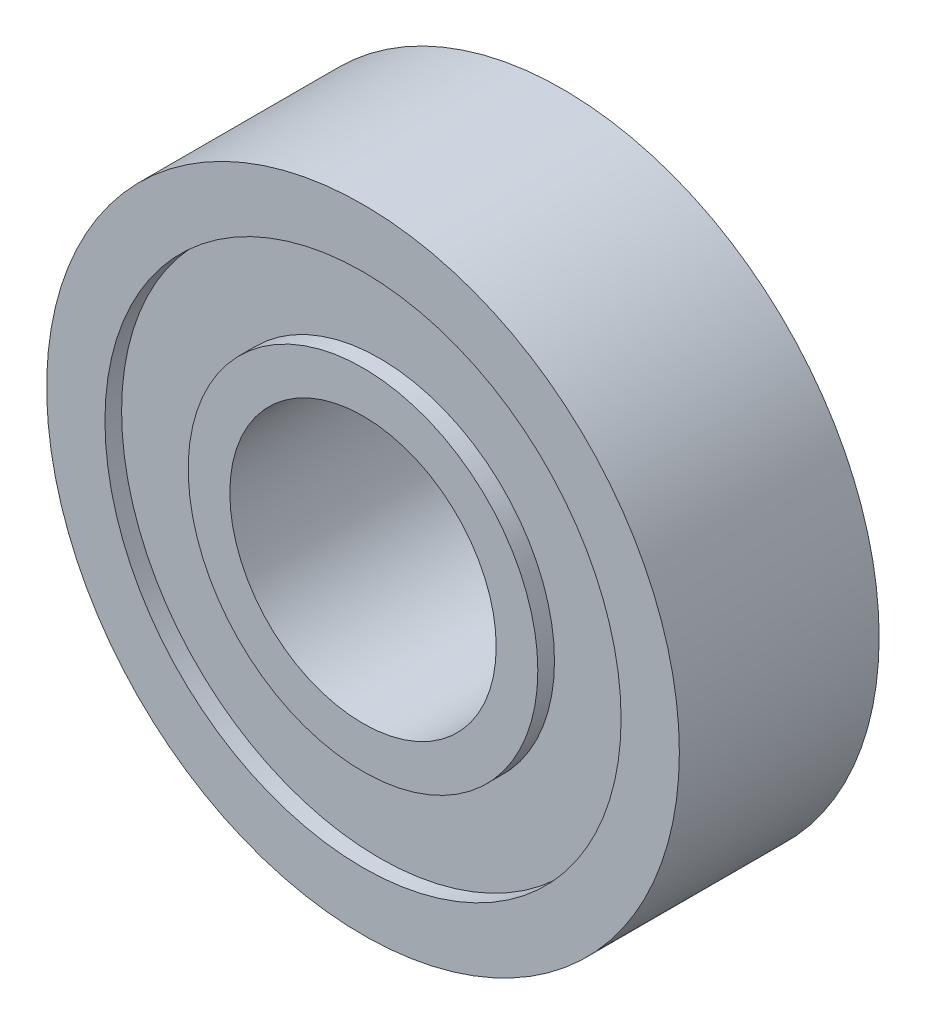
from build123d import *

# Parameters (mm, degrees)
SKETCH_1_R          = 9.5
EXTRUDE_1_DEPTH     = 3
SKETCH_2_R          = 4
CUT_EXTRUDE_1_DEPTH = 7
SKETCH_3_R          = 7.75
SKETCH_3_R_2        = 5.25
CUT_EXTRUDE_2_DEPTH = 0.5


with BuildPart() as part:
    # 草圖1 → 填料-伸長1 (new body, symmetric)
    with BuildSketch(Plane.XY):
        Circle(SKETCH_1_R)
    extrude(amount=EXTRUDE_1_DEPTH, both=True)

    # 草圖2 → 除料-伸長1 (cut, through all)
    with BuildSketch(Plane.XY.offset(3)):
        Circle(SKETCH_2_R)
    extrude(amount=-CUT_EXTRUDE_1_DEPTH, mode=Mode.SUBTRACT)

    # 草圖3 → 除料-伸長2 (cut)
    with BuildSketch(Plane.XY.offset(3)):
        Circle(SKETCH_3_R)
        Circle(SKETCH_3_R_2, mode=Mode.SUBTRACT)
    cut_extrude_2 = extrude(amount=-CUT_EXTRUDE_2_DEPTH, mode=Mode.SUBTRACT)

    # 鏡射1: 除料-伸長2 across plane
    add(cut_extrude_2.mirror(Plane.XY), mode=Mode.SUBTRACT)


solid = part.part
